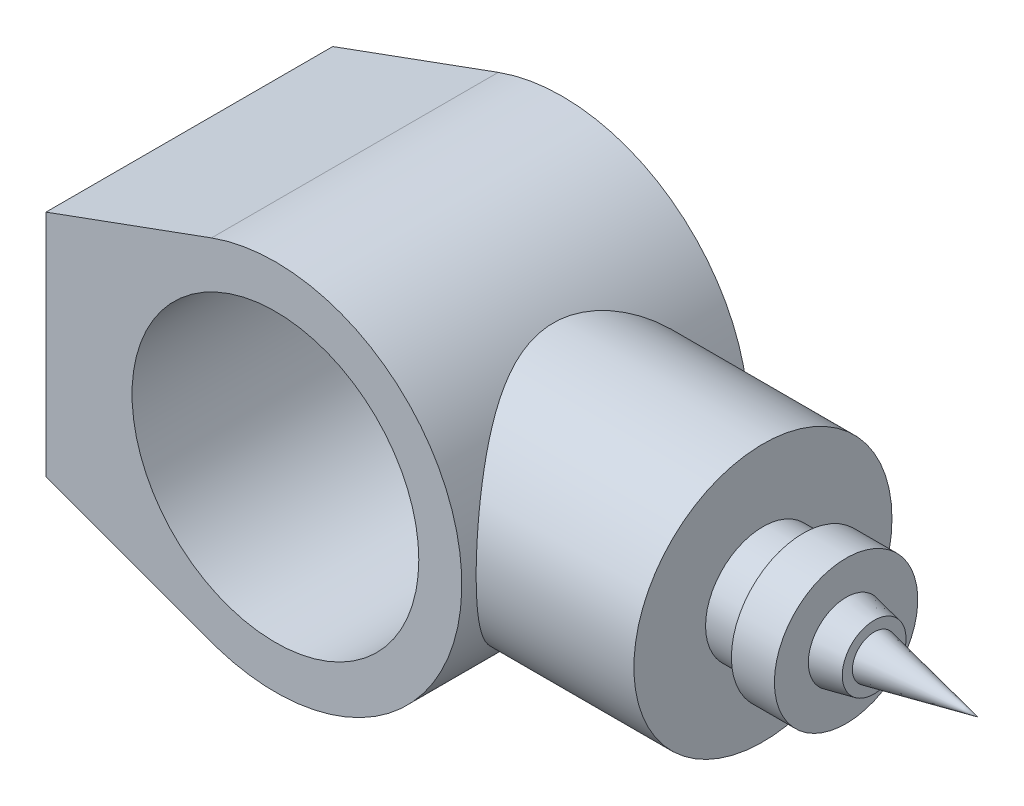
from build123d import *

# Parameters (mm, degrees)
SKETCH1_R           = 50
BOSS_EXTRUDE1_DEPTH = 50
BOSS_EXTRUDE2_REACH = 202
SKETCH2_R           = 45


with BuildPart() as part:
    # Sketch1 → Boss-Extrude1 (new body, symmetric)
    with BuildSketch(Plane.XY):
        with BuildLine():
            Line((-80, -40), (-80, 40))
            Line((-80, 40), (-22.281665693, 61.061668614))
            ThreePointArc((-22.281665693, 61.061668614), (64.99323144, 0.938012287), (-20.510212, -61.679260726))
            Line((-20.510212, -61.679260726), (-80, -40))
        make_face()
        Circle(SKETCH1_R, mode=Mode.SUBTRACT)
    extrude(amount=BOSS_EXTRUDE1_DEPTH, both=True)


with BuildPart() as body_2:

    # Sketch2 → Boss-Extrude2 (new body, up to next)
    with BuildSketch(Plane(origin=(120, 0, 0), x_dir=(0, 0, -1), z_dir=(1, 0, 0)), mode=Mode.PRIVATE) as boss_extrude2_sk1:
        Circle(SKETCH2_R)
    boss_extrude2_tool1 = extrude(boss_extrude2_sk1.sketch, amount=-BOSS_EXTRUDE2_REACH, mode=Mode.PRIVATE) - part.part
    add(boss_extrude2_tool1.solids().sort_by_distance((120, 0, 0))[0])

    # Sketch3 → Revolve1 (revolve)
    with BuildSketch(Plane.XY):
        Polygon((120, 0), (120, -20), (134, -20), (134, -25), (149, -25), (149, -13.171383635), (158.787234043, -11.119543048), (158.787234043, -7.591810174), (195, 0), align=None)
    revolve(axis=Axis((0, 0, 0), (1, 0, 0)))


solid = Compound([part.part, body_2.part])
